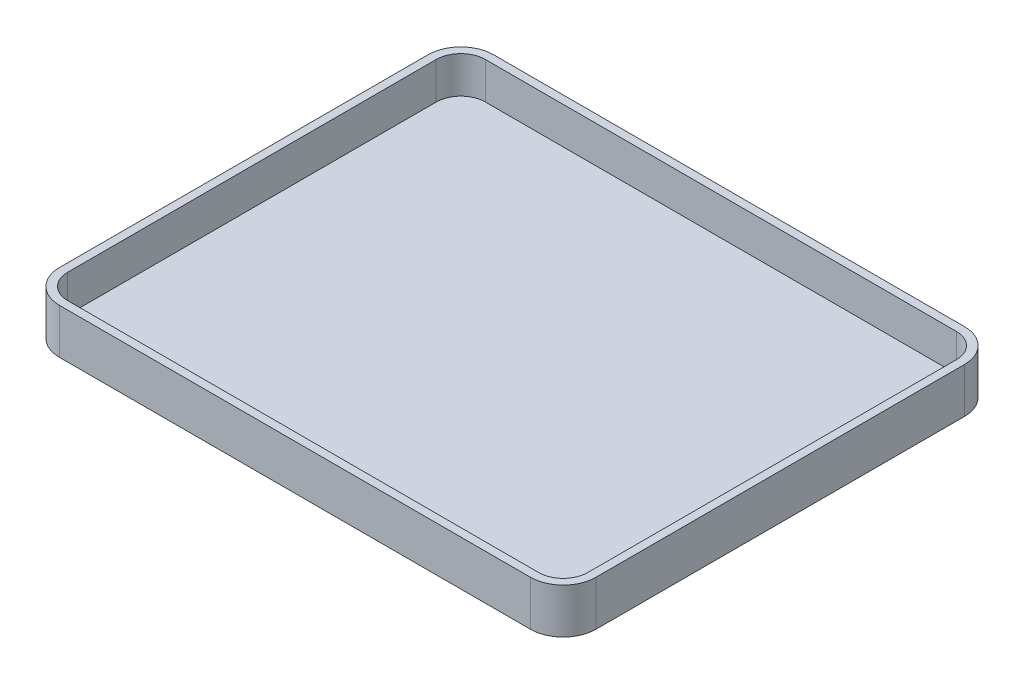
from build123d import *

# Parameters (mm, degrees)
CROQUIS1_W              = 131
CROQUIS1_H              = 106
SALIENTE_EXTRUIR2_DEPTH = 11
REDONDEO1_R             = 8
VACIADO1_T              = -2
CROQUIS3_RX             = 2.690749
CROQUIS3_RY             = 1.964902
CORTAR_EXTRUIR1_DEPTH   = 1


with BuildPart() as part:
    # Croquis1 → Saliente-Extruir2 (new body)
    with BuildSketch(Plane(origin=(0, 0, 0), x_dir=(1, 0, 0), z_dir=(0, 1, 0))):
        Rectangle(CROQUIS1_W, CROQUIS1_H)
    extrude(amount=SALIENTE_EXTRUIR2_DEPTH)

    # Redondeo1
    redondeo1_edges = [part.edges().sort_by_distance(p)[0] for p in [
        (65.5, 5.5, -53),
        (65.5, 5.5, 53),
        (-65.5, 5.5, 53),
        (-65.5, 5.5, -53),
    ]]
    fillet(redondeo1_edges, radius=REDONDEO1_R)

    # Vaciado1
    vaciado1_openings = [part.faces().sort_by_distance(p)[0] for p in [
        (0, 11, 0),
    ]]
    offset(amount=VACIADO1_T, openings=vaciado1_openings, kind=Kind.INTERSECTION)

    # Croquis3 → Cortar-Extruir1 (cut)
    with BuildSketch(Plane.XZ):
        with BuildLine():
            Line((-43.795749, -0.602015), (-44.773366, -0.210969))
            Line((-44.773366, -0.210969), (-45.675845, 0.983327))
            add(Edge.make_bspline(
                [(-46.038788, 1.442274), (-45.675845, 0.983327)],
                knots=[0, 0, 1, 1], degree=1))
            add(Edge.make_bspline(
                [(-46.038788, 1.442274), (-46.166808, 2.239237), (-46.494604, 3.029178), (-46.422847, 3.833162), (-46.027726, 8.260176), (-39.638852, 13.780407), (-35.221321, 13.122825)],
                knots=[0, 0, 0, 0, 1, 1, 1, 2, 2, 2, 2], degree=3))
            add(Edge.make_bspline(
                [(-35.221321, 13.122825), (-35.287745, 13.05655), (-35.336619, 12.965868), (-35.420593, 12.923998), (-36.13806, 12.566264), (-36.904939, 12.310496), (-37.611242, 11.931195), (-37.933411, 11.758183), (-38.095256, 11.323254), (-38.408327, 11.135886), (-42.558988, 8.651781), (-43.442222, 3.927774), (-43.795749, -0.602015)],
                knots=[0, 0, 0, 0, 1, 1, 1, 2, 2, 2, 3, 3, 3, 4, 4, 4, 4], degree=3))
        make_face()
        Polygon((-16.30933, 8.149098), (-12.726445, 7.950049), (-10.138805, 0.784277), (-7.551165, 8.149098), (-3.96828, 7.950049), (-4.167329, -3.395756), (-6.35687, -3.196707), (-6.555919, 4.168114), (-9.143559, -3.395756), (-11.3331, -3.196707), (-13.92074, 4.367163), (-14.119789, -3.395756), (-16.508379, -3.196707), align=None)
        with BuildLine():
            Line((5.98418, 0.386179), (0.012704, -0.011919))
            ThreePointArc((0.012704, -0.011919), (1.613105, -1.790209), (3.794639, -0.808116))
            Line((3.794639, -0.808116), (5.586082, -1.007165))
            add(Edge.make_bspline(
                [(5.586082, -1.007165), (5.275047, -2.251304), (4.204318, -3.461003), (2.799393, -3.594805), (-1.274647, -3.982809), (-2.653668, -1.711328), (-2.375886, 2.177622), (-2.369201, 2.271216), (-2.2188, 2.292744), (-2.176837, 2.376671), (-1.609225, 3.511895), (-0.950376, 5.014767), (0.609852, 5.16336), (1.602814, 5.257928), (2.605837, 5.08803), (3.59559, 4.964311), (3.688698, 4.952672), (3.722555, 4.825332), (3.794639, 4.765261), (5.386818, 3.438446), (5.64222, 2.437937), (5.98418, 0.386179)],
                knots=[0, 0, 0, 0, 1, 1, 1, 2, 2, 2, 3, 3, 3, 4, 4, 4, 5, 5, 5, 6, 6, 6, 7, 7, 7, 7], degree=3))
        make_face()
        with BuildLine():
            Line((2.799393, 3.172868), (3.396541, 1.978573))
            Line((3.396541, 1.978573), (0.012704, 1.978573))
            add(Edge.make_bspline(
                [(0.012704, 1.978573), (0.660456, 3.597952), (1.06545, 3.389611), (2.799393, 3.172868)],
                knots=[0, 0, 0, 0, 1, 1, 1, 1], degree=3))
        make_face(mode=Mode.SUBTRACT)
        with BuildLine():
            Line((12.950902, 8.149098), (15.339492, 7.950049))
            Line((15.339492, 7.950049), (15.140443, -3.395756))
            Line((15.140443, -3.395756), (13.149951, -3.196707))
            add(Edge.make_bspline(
                [(13.149951, -3.196707), (13.502675, -2.478207), (12.950902, -2.599559)],
                knots=[0, 0, 0, 1, 1, 1], degree=2))
            add(Edge.make_bspline(
                [(12.950902, -2.599559), (12.342951, -3.20751), (12.194581, -3.533916), (11.159459, -3.594805), (5.355711, -3.936202), (6.005808, 4.266873), (8.969918, 4.964311), (10.868103, 5.410942), (11.747726, 5.37129), (12.950902, 4.168114)],
                knots=[0, 0, 0, 0, 1, 1, 1, 2, 2, 2, 3, 3, 3, 3], degree=3))
            Line((12.950902, 4.168114), (12.950902, 8.149098))
        make_face()
        with Locations(Location((11.119415, 0.820588), (0, 0, -89.234345))):
            Ellipse(CROQUIS3_RX, CROQUIS3_RY, mode=Mode.SUBTRACT)
        Polygon((16.334738, 4.964311), (18.723329, 4.765261), (20.116673, -0.210969), (21.510018, 4.964311), (23.898608, 4.765261), (25.291952, -0.210969), (26.685297, 4.964311), (29.073887, 4.765261), (26.486248, -3.395756), (23.898608, -3.196707), (22.704313, 1.580474), (21.310968, -3.395756), (18.723329, -3.196707), align=None)
        with BuildLine():
            Line((32.059625, 2.376671), (30.08935, 2.376671))
            add(Edge.make_bspline(
                [(30.08935, 2.376671), (30.23612, 3.142053), (30.201901, 3.755952), (30.92886, 4.148229), (31.320559, 4.359595), (31.745621, 4.504802), (32.137319, 4.716168), (32.219896, 4.760728), (32.247343, 4.9126), (32.341148, 4.910319), (36.210969, 4.816219), (35.413768, 5.56188), (36.510269, 4.410725), (36.833855, 4.071009), (37.41141, 3.855549), (37.481027, 3.391579), (37.826172, 1.0913), (37.633443, -1.257981), (37.709651, -3.582762)],
                knots=[0, 0, 0, 0, 1, 1, 1, 2, 2, 2, 3, 3, 3, 4, 4, 4, 5, 5, 5, 6, 6, 6, 6], degree=3))
            add(Edge.make_bspline(
                [(37.709651, -3.582762), (36.645261, -3.665877), (35.715014, -3.833325), (34.968233, -2.943431)],
                knots=[0, 0, 0, 0, 1, 1, 1, 1], degree=3))
            add(Edge.make_bspline(
                [(34.968233, -2.943431), (34.827507, -3.067587), (34.727449, -3.267784), (34.546056, -3.315898), (33.892035, -3.489376), (33.211197, -3.59564), (32.534593, -3.588948), (31.9338, -3.583005), (31.27864, -3.580165), (30.759072, -3.278442), (29.534825, -2.567499), (29.807826, -1.350249), (29.753515, -0.223965)],
                knots=[0, 0, 0, 0, 1, 1, 1, 2, 2, 2, 3, 3, 3, 4, 4, 4, 4], degree=3))
            add(Edge.make_bspline(
                [(29.753515, -0.223965), (30.019445, 0.009921), (30.067175, 0.447146), (30.357306, 0.650234), (30.802347, 0.961757), (31.326443, 1.1752), (31.858611, 1.284312), (33.877802, 1.69831), (34.408947, 0.826307), (35.031398, 2.358974)],
                knots=[0, 0, 0, 0, 1, 1, 1, 2, 2, 2, 3, 3, 3, 3], degree=3))
            add(Edge.make_bspline(
                [(34.832349, 2.956122), (35.031398, 2.358974)],
                knots=[0, 0, 1, 1], degree=1))
            add(Edge.make_bspline(
                [(34.832349, 2.956122), (34.642001, 3.032879), (34.462262, 3.228112), (34.261306, 3.186392), (33.617934, 3.052821), (33.002542, 2.808785), (32.37316, 2.619982)],
                knots=[0, 0, 0, 0, 1, 1, 1, 2, 2, 2, 2], degree=3))
            Line((32.37316, 2.619982), (32.258674, 2.376671))
            add(Edge.make_bspline(
                [(32.059625, 2.376671), (32.258674, 2.376671)],
                knots=[0, 0, 1, 1], degree=1))
        make_face()
        with BuildLine():
            Line((35.443461, 0.52125), (35.236328, -1.069237))
            add(Edge.make_bspline(
                [(35.236328, -1.069237), (34.994852, -1.250227), (34.975423, -1.651492), (34.720777, -1.813428), (33.576076, -2.541374), (33.380334, -2.225953), (32.258674, -1.86992)],
                knots=[0, 0, 0, 0, 1, 1, 1, 2, 2, 2, 2], degree=3))
            add(Edge.make_bspline(
                [(32.258674, -1.86992), (31.675887, -1.499647), (31.980639, -0.808116)],
                knots=[0, 0, 0, 1, 1, 1], degree=2))
            add(Edge.make_bspline(
                [(31.980639, -0.808116), (32.160804, -0.537315), (32.238883, -0.157352), (32.521133, 0.004288), (33.379564, 0.495898), (34.46607, 0.36864), (35.443461, 0.52125)],
                knots=[0, 0, 0, 0, 1, 1, 1, 2, 2, 2, 2], degree=3))
        make_face(mode=Mode.SUBTRACT)
        with BuildLine():
            Line((38.429199, 4.964311), (41.016839, 4.765261))
            Line((41.016839, 4.765261), (42.609233, -0.410018))
            Line((42.609233, -0.410018), (44.400675, 4.964311))
            Line((44.400675, 4.964311), (46.789266, 4.765261))
            add(Edge.make_bspline(
                [(46.789266, 4.765261), (46.614359, 3.890729), (46.310216, 3.023348), (45.993069, 2.177622), (45.960122, 2.089763), (45.826086, 2.066756), (45.79402, 1.978573), (45.55729, 1.327567), (45.433602, 0.639086), (45.196872, -0.011919), (45.164806, -0.100103), (45.03077, -0.12311), (44.997823, -0.210969), (44.629466, -1.193254), (44.370934, -2.214421), (44.002577, -3.196707), (43.96963, -3.284565), (43.836475, -3.307898), (43.803528, -3.395756), (43.167713, -5.091261), (43.788156, -4.406374), (43.20638, -4.988149), (42.874632, -5.319898), (42.636282, -5.784993), (42.211134, -5.983395), (40.609817, -6.730677), (40.366009, -6.429949), (39.026347, -5.983395)],
                knots=[0, 0, 0, 0, 1, 1, 1, 2, 2, 2, 3, 3, 3, 4, 4, 4, 5, 5, 5, 6, 6, 6, 7, 7, 7, 8, 8, 8, 9, 9, 9, 9], degree=3))
            Line((39.026347, -5.983395), (39.225396, -4.191953))
            Line((39.225396, -4.191953), (40.618741, -4.391002))
            add(Edge.make_bspline(
                [(41.215888, -3.793854), (41.488471, -4.680656), (40.618741, -4.391002)],
                knots=[0, 0, 0, 1, 1, 1], degree=2))
            Line((41.215888, -3.793854), (38.429199, 4.964311))
        make_face()
        with BuildLine():
            add(Edge.make_bspline(
                [(-29.844676, -3.992903), (-29.252483, -3.777561), (-27.257036, -1.753818), (-27.257036, -2.599559), (-27.257036, -4.152351), (-29.906978, -6.341895), (-31.038971, -6.978641), (-35.26731, -9.357082), (-42.018585, -10.482685), (-44.773366, -5.585297), (-45.568719, -4.171334), (-46.365759, -2.256251), (-46.365759, -0.609067)],
                knots=[4, 4, 4, 4, 5, 5, 5, 6, 6, 6, 7, 7, 7, 8, 8, 8, 8], degree=3))
            add(Edge.make_bspline(
                [(-46.365759, -0.609067), (-46.16671, -0.675417), (-45.93245, -0.677045), (-45.768611, -0.808116), (-45.255714, -1.218434), (-44.859451, -1.757625), (-44.375267, -2.201461), (-42.03519, -4.346532), (-38.32614, -5.477634), (-35.219004, -5.386248), (-33.690861, -5.341302), (-31.36224, -4.544745), (-29.844676, -3.992903)],
                knots=[0, 0, 0, 0, 1, 1, 1, 2, 2, 2, 3, 3, 3, 4, 4, 4, 4], degree=3))
        make_face()
        with BuildLine():
            add(Edge.make_bspline(
                [(-38.204742, -10.362478), (-37.15726, -10.177628), (-36.076336, -10.287709), (-35.019955, -10.163429), (-32.36448, -9.85102), (-29.16459, -7.338824), (-27.456085, -5.386248), (-26.188569, -3.937658), (-25.083826, -1.697445), (-24.868446, 0.18713), (-24.491387, 3.486395), (-24.579262, 6.53918), (-26.26179, 9.343393), (-26.773429, 10.196124), (-27.535367, 10.974583), (-27.854184, 11.931032)],
                knots=[5, 5, 5, 5, 6, 6, 6, 7, 7, 7, 8, 8, 8, 9, 9, 9, 10, 10, 10, 10], degree=3))
            add(Edge.make_bspline(
                [(-27.854184, 11.931032), (-26.53144, 11.600347), (-25.625887, 10.498933), (-24.669396, 9.542442), (-19.517706, 4.390752), (-20.64398, -5.542642), (-26.858938, -9.367232), (-27.649258, -9.853583), (-29.475203, -11.00605), (-30.441823, -11.158675), (-32.434293, -11.473275), (-36.453595, -12.060707), (-38.403791, -10.760576), (-38.527236, -10.678279), (-38.350847, -10.388261), (-38.204742, -10.362478)],
                knots=[0, 0, 0, 0, 1, 1, 1, 2, 2, 2, 3, 3, 3, 4, 4, 4, 5, 5, 5, 5], degree=3))
        make_face()
    extrude(amount=-CORTAR_EXTRUIR1_DEPTH, mode=Mode.SUBTRACT)


solid = part.part
